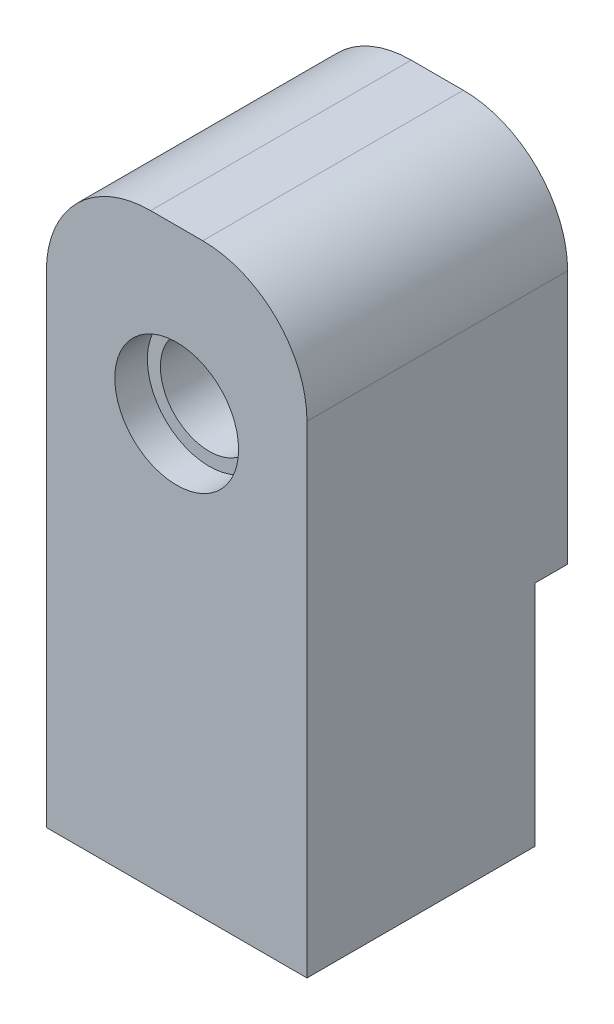
from build123d import *

# Parameters (mm, degrees)
SKETCH1_W           = 25.4
SKETCH1_H           = 57.15
BOSS_EXTRUDE1_DEPTH = 25.4
SKETCH2_R           = 6.0325
CUT_EXTRUDE1_DEPTH  = 3.175
CUT_EXTRUDE2_REACH  = 27.4
SKETCH3_R           = 4.7625
SKETCH4_W           = 25.4
SKETCH4_H           = 22.225
CUT_EXTRUDE4_DEPTH  = 3.175
SKETCH6_R           = 6.35
CUT_EXTRUDE5_DEPTH  = 30.1752
FILLET1_R           = 10.16


with BuildPart() as part:
    # Sketch1 → Boss-Extrude1 (new body)
    with BuildSketch(Plane.XY):
        Rectangle(SKETCH1_W, SKETCH1_H)
    extrude(amount=-BOSS_EXTRUDE1_DEPTH)

    # Sketch2 → Cut-Extrude1 (cut)
    with BuildSketch(Plane.XY):
        with Locations((0, 12.7)):
            Circle(SKETCH2_R)
    extrude(amount=-CUT_EXTRUDE1_DEPTH, mode=Mode.SUBTRACT)

    # Sketch3 → Cut-Extrude2 (cut, up to next)
    with BuildSketch(Plane(origin=(0, 0, -25.4), x_dir=(-1, 0, 0), z_dir=(0, 0, -1)), mode=Mode.PRIVATE) as cut_extrude2_sk1:
        with Locations((0, 12.7)):
            Circle(SKETCH3_R)
    cut_extrude2_tool1 = extrude(cut_extrude2_sk1.sketch, amount=-CUT_EXTRUDE2_REACH, mode=Mode.PRIVATE) & part.part
    add(cut_extrude2_tool1.solids().sort_by_distance((0, 12.7, -25.4))[0], mode=Mode.SUBTRACT)

    # Sketch4 → Cut-Extrude4 (cut)
    with BuildSketch(Plane(origin=(0, 0, -25.4), x_dir=(-1, 0, 0), z_dir=(0, 0, -1))):
        with Locations((0, -17.4625)):
            Rectangle(SKETCH4_W, SKETCH4_H)
    extrude(amount=-CUT_EXTRUDE4_DEPTH, mode=Mode.SUBTRACT)

    # Sketch6 → Cut-Extrude5 (cut)
    with BuildSketch(Plane.XZ.offset(28.575)):
        with Locations((0, -12.7)):
            Circle(SKETCH6_R)
    extrude(amount=-CUT_EXTRUDE5_DEPTH, mode=Mode.SUBTRACT)

    # Fillet1
    fillet1_edges = [part.edges().sort_by_distance(p)[0] for p in [
        (-12.7, 28.575, -12.7),
        (12.7, 28.575, -12.7),
    ]]
    fillet(fillet1_edges, radius=FILLET1_R)


solid = part.part
